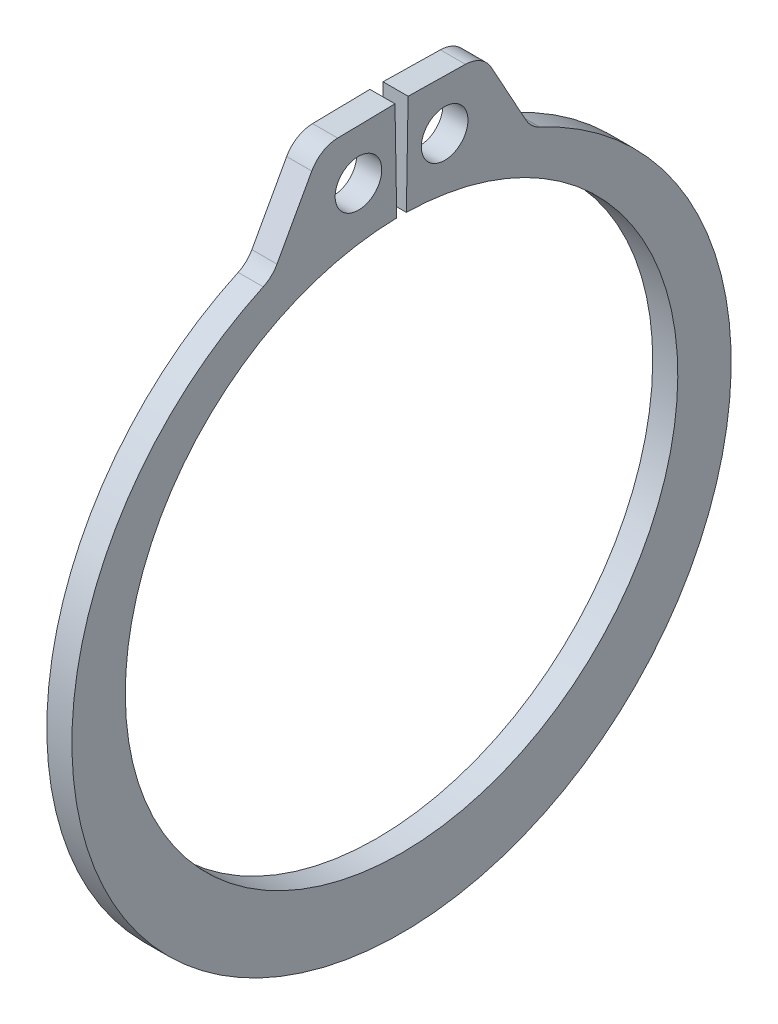
from build123d import *

# Parameters (mm, degrees)
SKETCH1_R      = 0.9906
EXTRUDE1_DEPTH = 0.5334
FILLET1_R      = 1.2827


with BuildPart() as part:
    # Sketch1 → Extrude1 (new body, symmetric)
    with BuildSketch(Plane(origin=(0, 0, 0), x_dir=(0, 0, -1), z_dir=(1, 0, 0))):
        with BuildLine():
            Line((-0.205022145, 11.745710799), (-0.279051762, 15.986864752))
            Line((-0.279051762, 15.986864752), (-3.459917227, 15.931342539))
            Line((-3.459917227, 15.931342539), (-5.505255869, 12.215234753))
            ThreePointArc((-5.505255869, 12.215234753), (0, -14.6939), (5.505255869, 12.215234753))
            Line((5.505255869, 12.215234753), (3.459917227, 15.931342539))
            Line((3.459917227, 15.931342539), (0.279051762, 15.986864752))
            Line((0.279051762, 15.986864752), (0.205022145, 11.745710799))
            ThreePointArc((0.205022145, 11.745710799), (0, -11.7475), (-0.205022145, 11.745710799))
        make_face()
        with Locations((-1.832469686, 13.838526669)):
            Circle(SKETCH1_R, mode=Mode.SUBTRACT)
        with Locations((1.832469686, 13.838526669)):
            Circle(SKETCH1_R, mode=Mode.SUBTRACT)
    extrude(amount=EXTRUDE1_DEPTH, both=True)

    # Fillet1
    fillet1_edges = [part.edges().sort_by_distance(p)[0] for p in [
        (0, 15.931342539, -3.459917227),
        (0, 12.215234753, -5.505255869),
        (0, 12.215234753, 5.505255869),
        (0, 15.931342539, 3.459917227),
    ]]
    fillet(fillet1_edges, radius=FILLET1_R)


solid = part.part
